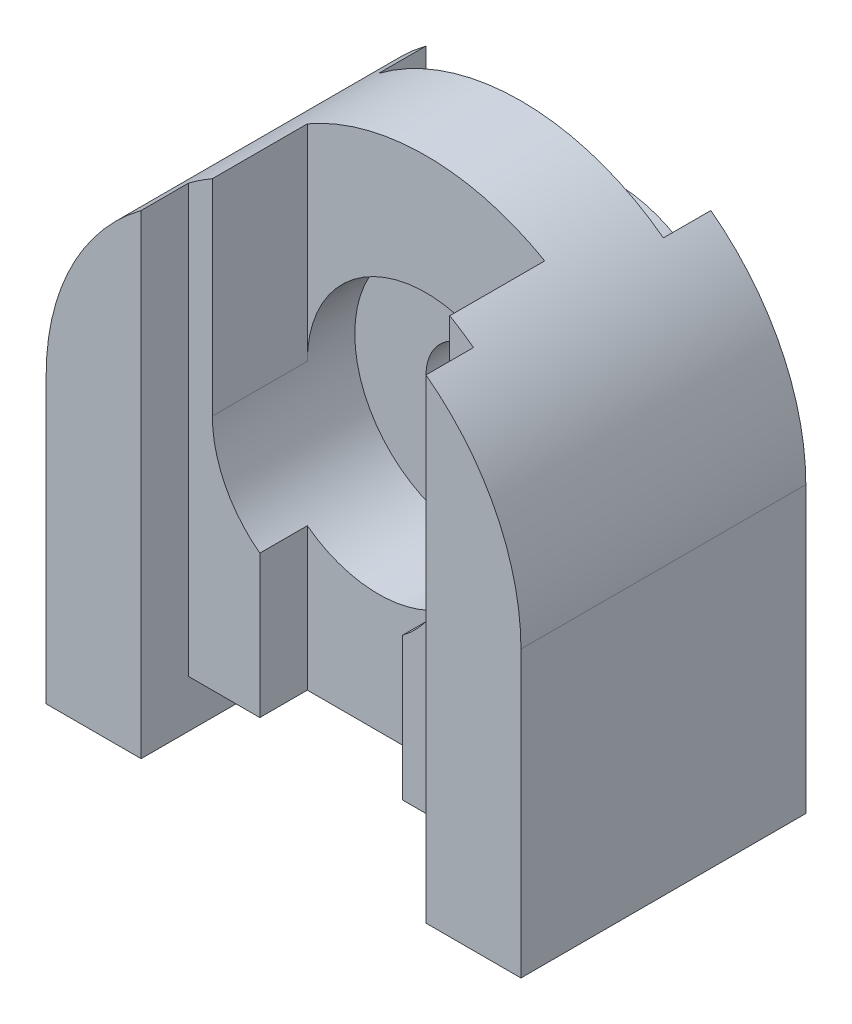
from build123d import *

# Parameters (mm, degrees)
SKETCH1_W           = 100
SKETCH1_H           = 110
BOSS_EXTRUDE1_DEPTH = 70
SKETCH2_W           = 60
SKETCH2_H           = 10
CUT_EXTRUDE1_DEPTH  = 70
CUT_EXTRUDE2_DEPTH  = 70
SKETCH4_R           = 10
CUT_EXTRUDE3_DEPTH  = 30
SKETCH5_W           = 100
SKETCH5_H           = 10
CUT_EXTRUDE4_DEPTH  = 185
SKETCH7_W           = 60
SKETCH7_H           = 10
CUT_EXTRUDE5_DEPTH  = 200
SKETCH8_R           = 25
SKETCH8_R_2         = 10
BOSS_EXTRUDE3_DEPTH = 20
SKETCH9_R           = 25
CUT_EXTRUDE7_DEPTH  = 40
CUT_EXTRUDE8_DEPTH  = 30
SKETCH11_W          = 60
SKETCH11_H          = 10
CUT_EXTRUDE9_DEPTH  = 130
SKETCH12_W          = 30
SKETCH12_H          = 10
CUT_EXTRUDE10_DEPTH = 130


with BuildPart() as part:
    # Sketch1 → Boss-Extrude1 (new body)
    with BuildSketch(Plane.XY):
        with Locations((50, 55)):
            Rectangle(SKETCH1_W, SKETCH1_H)
    extrude(amount=BOSS_EXTRUDE1_DEPTH)

    # Sketch2 → Cut-Extrude1 (cut)
    with BuildSketch(Plane.XY.offset(70)):
        with Locations((50, 5)):
            Rectangle(SKETCH2_W, SKETCH2_H)
    extrude(amount=-CUT_EXTRUDE1_DEPTH, mode=Mode.SUBTRACT)

    # Sketch3 → Cut-Extrude2 (cut)
    with BuildSketch(Plane.XY.offset(70)):
        with BuildLine():
            Line((0, 110), (0, 60))
            ThreePointArc((0, 60), (14.644660941, 95.355339059), (50, 110))
            Line((50, 110), (0, 110))
        make_face()
        with BuildLine():
            Line((100, 110), (50, 110))
            ThreePointArc((50, 110), (85.355339059, 95.355339059), (100, 60))
            Line((100, 60), (100, 110))
        make_face()
    extrude(amount=-CUT_EXTRUDE2_DEPTH, mode=Mode.SUBTRACT)

    # Sketch4 → Cut-Extrude3 (cut)
    with BuildSketch(Plane(origin=(0, 0, 0), x_dir=(-1, 0, 0), z_dir=(0, 0, -1))):
        with Locations((-50, 60)):
            Circle(SKETCH4_R)
    extrude(amount=-CUT_EXTRUDE3_DEPTH, mode=Mode.SUBTRACT)

    # Sketch5 → Cut-Extrude4 (cut)
    with BuildSketch(Plane.XZ):
        with Locations((50, 5)):
            Rectangle(SKETCH5_W, SKETCH5_H)
    extrude(amount=-CUT_EXTRUDE4_DEPTH, mode=Mode.SUBTRACT)

    # Sketch7 → Cut-Extrude5 (cut)
    with BuildSketch(Plane(origin=(0, 10, 0), x_dir=(-1, 0, 0), z_dir=(0, -1, 0))):
        with Locations((-50, -15)):
            Rectangle(SKETCH7_W, SKETCH7_H)
    extrude(amount=-CUT_EXTRUDE5_DEPTH, mode=Mode.SUBTRACT)

    # Sketch8 → Boss-Extrude3 (add)
    with BuildSketch(Plane(origin=(0, 0, 20), x_dir=(-1, 0, 0), z_dir=(0, 0, -1))):
        with Locations((-50, 60)):
            Circle(SKETCH8_R)
        with Locations((-50, 60)):
            Circle(SKETCH8_R_2, mode=Mode.SUBTRACT)
    extrude(amount=BOSS_EXTRUDE3_DEPTH)

    # Sketch9 → Cut-Extrude7 (cut)
    with BuildSketch(Plane.XY.offset(70)):
        with Locations((50, 60)):
            Circle(SKETCH9_R)
    extrude(amount=-CUT_EXTRUDE7_DEPTH, mode=Mode.SUBTRACT)

    # Sketch10 → Cut-Extrude8 (cut)
    with BuildSketch(Plane.XY.offset(70)):
        with BuildLine():
            Line((25, 103.301270189), (25, 60))
            ThreePointArc((25, 60), (50, 85), (75, 60))
            Line((75, 60), (75, 103.301270189))
            ThreePointArc((75, 103.301270189), (50, 110), (25, 103.301270189))
        make_face()
    extrude(amount=-CUT_EXTRUDE8_DEPTH, mode=Mode.SUBTRACT)

    # Sketch11 → Cut-Extrude9 (cut)
    with BuildSketch(Plane(origin=(0, 10, 0), x_dir=(-1, 0, 0), z_dir=(0, -1, 0))):
        with Locations((-50, -65)):
            Rectangle(SKETCH11_W, SKETCH11_H)
    extrude(amount=-CUT_EXTRUDE9_DEPTH, mode=Mode.SUBTRACT)

    # Sketch12 → Cut-Extrude10 (cut)
    with BuildSketch(Plane.XZ.offset(-10)):
        with Locations((50, 55)):
            Rectangle(SKETCH12_W, SKETCH12_H)
    extrude(amount=-CUT_EXTRUDE10_DEPTH, mode=Mode.SUBTRACT)


solid = part.part
